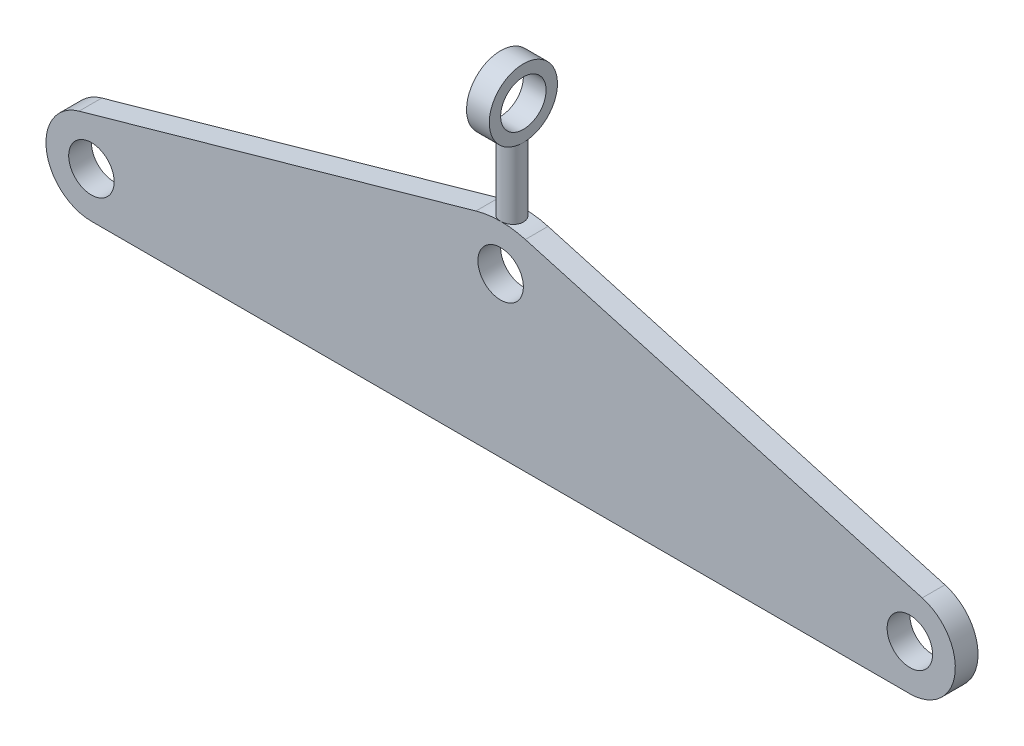
from build123d import *
from build123d.topology import SkipClean

# Parameters (mm, degrees)
SKETCH_1_R           = 10
EXTRUDE_1_DEPTH      = 10
EXTRUDE_START        = -85
SKETCH_2_R           = 5
EXTRUDE_2_DEPTH      = 40
EXTRUDE_3_DEPTH      = 5
EXTRUDE_3_DEPTH_BACK = 5
SKETCH_3_R           = 15
SKETCH_3_R_2         = 10


with BuildPart() as part:
    # 草图1 → 凸台-拉伸1 (new body)
    with BuildSketch(Plane.XY):
        with BuildLine():
            Line((-10.860669242, 88.497348787), (-185.430334621, 39.248674393))
            ThreePointArc((-185.430334621, 39.248674393), (-199.8112782, 17.258968065), (-180, 0))
            Line((-180, 0), (180, 0))
            ThreePointArc((180, 0), (199.8112782, 17.258968065), (185.430334621, 39.248674393))
            Line((185.430334621, 39.248674393), (10.860669242, 88.497348787))
            ThreePointArc((10.860669242, 88.497348787), (0, 90), (-10.860669242, 88.497348787))
        make_face()
        with Locations((-180, 20)):
            Circle(SKETCH_1_R, mode=Mode.SUBTRACT)
        with Locations((180, 20)):
            Circle(SKETCH_1_R, mode=Mode.SUBTRACT)
        with Locations((0, 70)):
            Circle(SKETCH_1_R, mode=Mode.SUBTRACT)
    extrude(amount=EXTRUDE_1_DEPTH)

    # 草图2 → 凸台-拉伸2 (add)
    with BuildSketch(Plane.XZ.offset(EXTRUDE_START)):
        with Locations((0, 5)):
            Circle(SKETCH_2_R)
    extrude(amount=-EXTRUDE_2_DEPTH)

    # 草图3 → 凸台-拉伸3 (add, two sides: drawn at the far end of the back side and taken through both)
    with SkipClean():  # the faces are left unmerged after this step: merging them gives an invalid solid
        with BuildSketch(Plane(origin=(0, 0, 0), x_dir=(0, 0, -1), z_dir=(1, 0, 0)).offset(-EXTRUDE_3_DEPTH_BACK)):
            with Locations((-5, 135)):
                Circle(SKETCH_3_R)
            with Locations((-5, 135)):
                Circle(SKETCH_3_R_2, mode=Mode.SUBTRACT)
        extrude(amount=EXTRUDE_3_DEPTH + EXTRUDE_3_DEPTH_BACK)


solid = part.part
